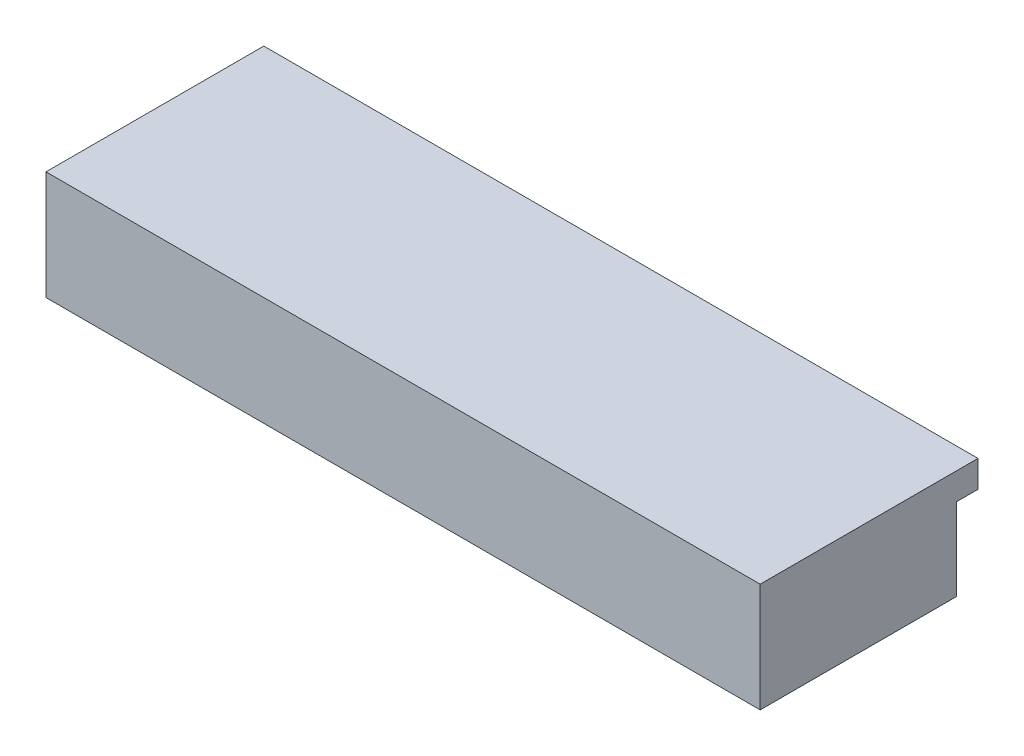
from build123d import *

# Parameters (mm, degrees)
ESQUISSE3_W      = 400
ESQUISSE3_H      = 40
EXTRUSION1_DEPTH = 110
ESQUISSE8_W      = 400
ESQUISSE8_H      = 122
EXTRUSION3_DEPTH = 15
ESQUISSE11_W     = 400
ESQUISSE11_H     = 110
EXTRUSION5_DEPTH = 6
ESQUISSE10_R     = 3
EXTRUSION4_DEPTH = 1.5
ESQUISSE12_R     = 3
EXTRUSION6_DEPTH = 20


with BuildPart() as part:
    # Esquisse3 → Extrusion1 (new body)
    with BuildSketch(Plane.XY):
        with Locations((38, 5)):
            Rectangle(ESQUISSE3_W, ESQUISSE3_H)
    extrude(amount=EXTRUSION1_DEPTH)

    # Esquisse8 → Extrusion3 (add)
    with BuildSketch(Plane(origin=(0, 25, 0), x_dir=(1, 0, 0), z_dir=(0, 1, 0))):
        with Locations((38, -49)):
            Rectangle(ESQUISSE8_W, ESQUISSE8_H)
    extrude(amount=EXTRUSION3_DEPTH)

    # Esquisse11 → Extrusion5 (add)
    with BuildSketch(Plane.XZ.offset(15)):
        with Locations((38, 55)):
            Rectangle(ESQUISSE11_W, ESQUISSE11_H)
    extrude(amount=EXTRUSION5_DEPTH)

    # Esquisse10 → Extrusion4 (cut)
    with BuildSketch(Plane(origin=(0, 0, 0), x_dir=(-1, 0, 0), z_dir=(0, 0, -1))):
        with BuildLine():
            Line((59.5, -8), (59.5, -19))
            ThreePointArc((59.5, -19), (58.914213562, -20.414213562), (57.5, -21))
            Line((57.5, -21), (-68.5, -21))
            ThreePointArc((-68.5, -21), (-69.914213562, -20.414213562), (-70.5, -19))
            Line((-70.5, -19), (-70.5, -8))
            ThreePointArc((-70.5, -8), (-71.085786438, -6.585786438), (-72.5, -6))
            Line((-72.5, -6), (-83, -6))
            ThreePointArc((-83, -6), (-95.5, 6.5), (-83, 19))
            Line((-83, 19), (70.25, 19))
            ThreePointArc((70.25, 19), (82.75, 6.5), (70.25, -6))
            Line((70.25, -6), (61.5, -6))
            ThreePointArc((61.5, -6), (60.085786438, -6.585786438), (59.5, -8))
        make_face()
        with Locations((-86.5, 6.5)):
            Circle(ESQUISSE10_R, mode=Mode.SUBTRACT)
        with Locations((-20.5, 6.5)):
            Circle(ESQUISSE10_R, mode=Mode.SUBTRACT)
        with Locations((72.75, 6.5)):
            Circle(ESQUISSE10_R, mode=Mode.SUBTRACT)
        with BuildLine():
            Line((-31.5, -3), (-61.5, -3))
            ThreePointArc((-61.5, -3), (-62.207106781, -2.707106781), (-62.5, -2))
            Line((-62.5, -2), (-62.5, 12))
            ThreePointArc((-62.5, 12), (-62.207106781, 12.707106781), (-61.5, 13))
            Line((-61.5, 13), (-31.5, 13))
            ThreePointArc((-31.5, 13), (-30.792893219, 12.707106781), (-30.5, 12))
            Line((-30.5, 12), (-30.5, -2))
            ThreePointArc((-30.5, -2), (-30.792893219, -2.707106781), (-31.5, -3))
        make_face(mode=Mode.SUBTRACT)
        with BuildLine():
            Line((51.75, 0), (12.75, 0))
            ThreePointArc((12.75, 0), (12.042893219, 0.292893219), (11.75, 1))
            Line((11.75, 1), (11.75, 11))
            ThreePointArc((11.75, 11), (12.042893219, 11.707106781), (12.75, 12))
            Line((12.75, 12), (51.75, 12))
            ThreePointArc((51.75, 12), (52.457106781, 11.707106781), (52.75, 11))
            Line((52.75, 11), (52.75, 1))
            ThreePointArc((52.75, 1), (52.457106781, 0.292893219), (51.75, 0))
        make_face(mode=Mode.SUBTRACT)
    extrude(amount=-EXTRUSION4_DEPTH, mode=Mode.SUBTRACT)

    # Esquisse12 → Extrusion6 (cut)
    with BuildSketch(Plane(origin=(0, 0, 0), x_dir=(-1, 0, 0), z_dir=(0, 0, -1))):
        with Locations((-86.5, 6.5)):
            Circle(ESQUISSE12_R)
        with Locations((-20.5, 6.5)):
            Circle(ESQUISSE12_R)
        with Locations((72.75, 6.5)):
            Circle(ESQUISSE12_R)
        with BuildLine():
            Line((-30.5, -2), (-30.5, 12))
            ThreePointArc((-30.5, 12), (-30.792893219, 12.707106781), (-31.5, 13))
            Line((-31.5, 13), (-61.5, 13))
            ThreePointArc((-61.5, 13), (-62.207106781, 12.707106781), (-62.5, 12))
            Line((-62.5, 12), (-62.5, -2))
            ThreePointArc((-62.5, -2), (-62.207106781, -2.707106781), (-61.5, -3))
            Line((-61.5, -3), (-31.5, -3))
            ThreePointArc((-31.5, -3), (-30.792893219, -2.707106781), (-30.5, -2))
        make_face()
        with BuildLine():
            Line((52.75, 1), (52.75, 11))
            ThreePointArc((52.75, 11), (52.457106781, 11.707106781), (51.75, 12))
            Line((51.75, 12), (12.75, 12))
            ThreePointArc((12.75, 12), (12.042893219, 11.707106781), (11.75, 11))
            Line((11.75, 11), (11.75, 1))
            ThreePointArc((11.75, 1), (12.042893219, 0.292893219), (12.75, 0))
            Line((12.75, 0), (51.75, 0))
            ThreePointArc((51.75, 0), (52.457106781, 0.292893219), (52.75, 1))
        make_face()
    extrude(amount=-EXTRUSION6_DEPTH, mode=Mode.SUBTRACT)


solid = part.part
